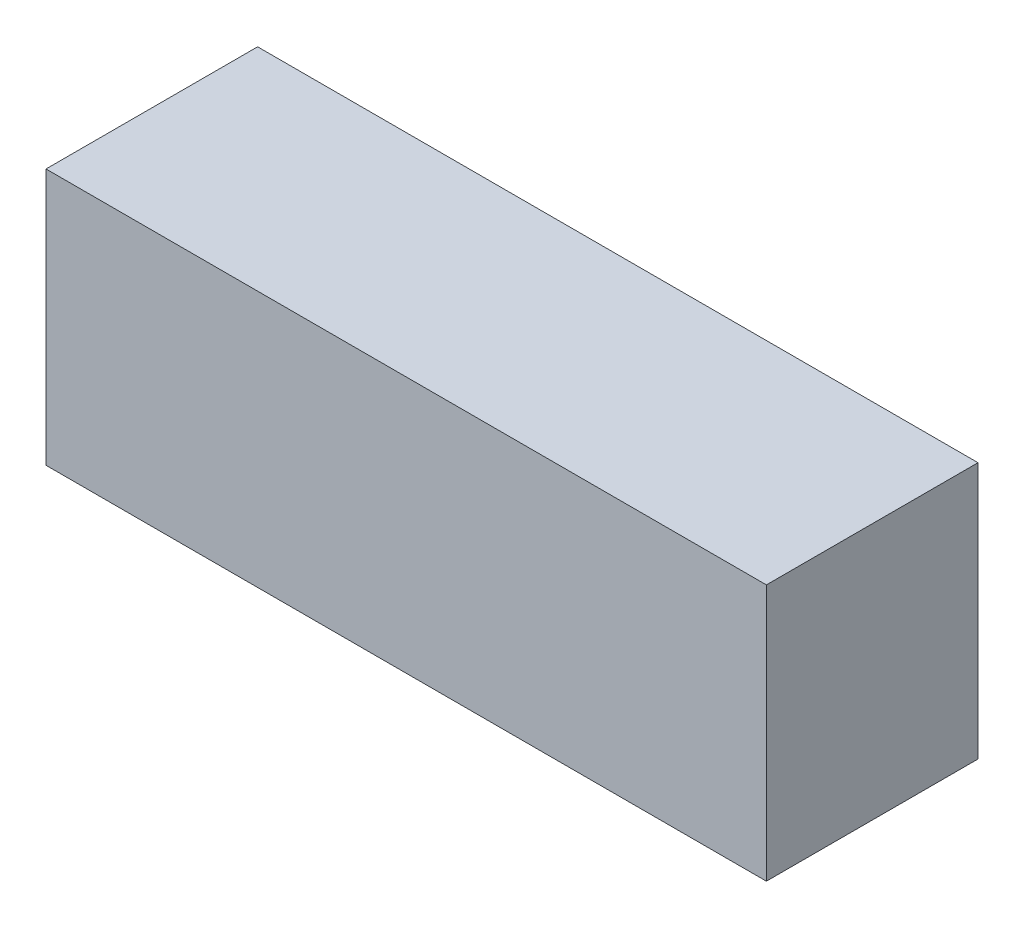
from build123d import *

# Parameters (mm, degrees)
SKETCH_1_W      = 160
SKETCH_1_H      = 57
EXTRUDE_1_DEPTH = 47


with BuildPart() as part:
    # Эскиз1 → Бобышка-Вытянуть1 (new body)
    with BuildSketch(Plane.XY):
        Rectangle(SKETCH_1_W, SKETCH_1_H)
    extrude(amount=EXTRUDE_1_DEPTH)


solid = part.part
